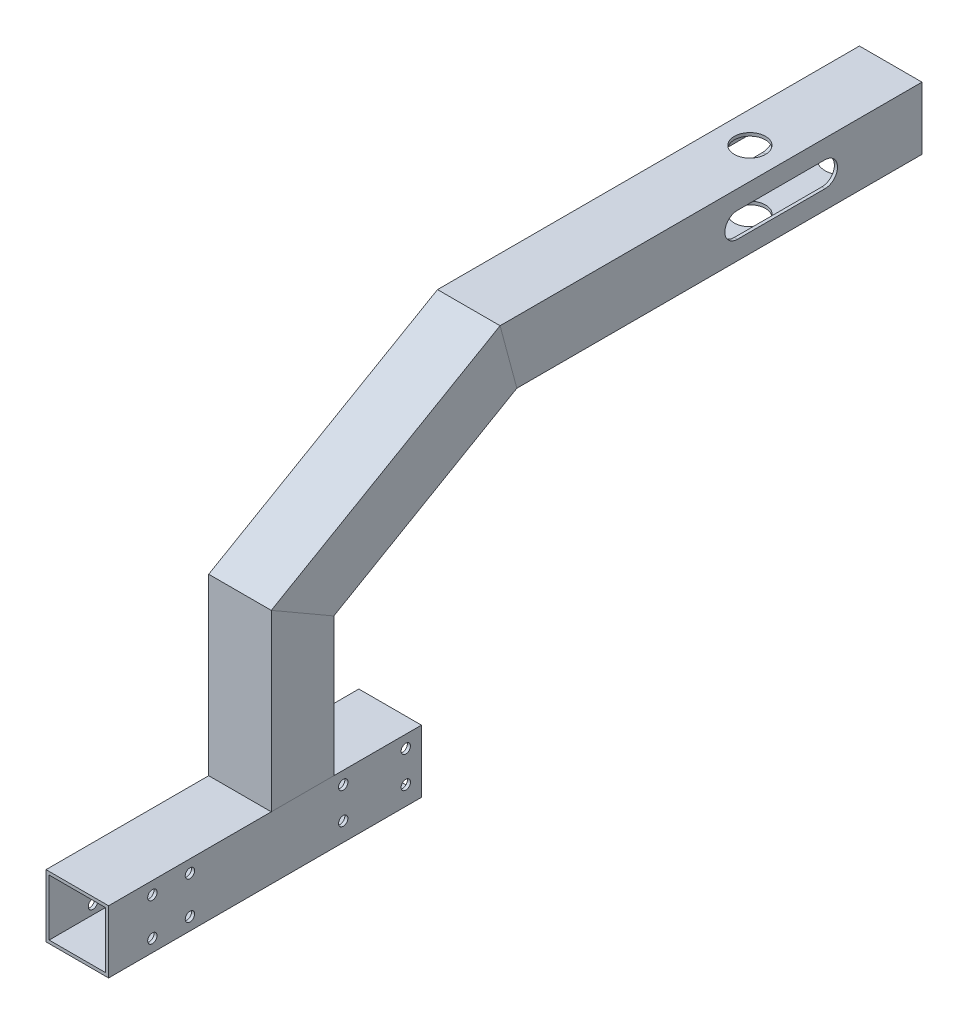
from build123d import *

# Parameters (mm, degrees)
SKETCH_11_W                = 20
SKETCH_11_H                = 20
SKETCH_11_W_2              = 18
SKETCH_11_H_2              = 18
F_20X20X1_14_DEPTH         = 100
SKETCH_11_ON_SEGMENT_2_W   = 20
SKETCH_11_ON_SEGMENT_2_H   = 20
SKETCH_11_ON_SEGMENT_2_W_2 = 18
SKETCH_11_ON_SEGMENT_2_H_2 = 18
F_20X20X1_14_2_DEPTH       = 70.164965809
SKETCH_11_ON_SEGMENT_3_W   = 20
SKETCH_11_ON_SEGMENT_3_H   = 20
SKETCH_11_ON_SEGMENT_3_W_2 = 18
SKETCH_11_ON_SEGMENT_3_H_2 = 18
F_20X20X1_14_3_DEPTH       = 89.954339629
SKETCH_11_ON_SEGMENT_4_W   = 20
SKETCH_11_ON_SEGMENT_4_H   = 20
SKETCH_11_ON_SEGMENT_4_W_2 = 18
SKETCH_11_ON_SEGMENT_4_H_2 = 18
F_20X20X1_14_4_DEPTH       = 136.971443132
SKETCH_12_R                = 1.5
CUT_EXTRUDE_1_DEPTH        = 283.248117797
SKETCH_13_R                = 5
CUT_EXTRUDE_2_DEPTH        = 279.035968896
CUT_EXTRUDE_3_DEPTH        = 283.248117797
SKETCH_15_R                = 6
CUT_EXTRUDE_4_DEPTH        = 1
SKETCH_16_R                = 1.5
CUT_EXTRUDE_5_DEPTH        = 1
SKETCH_17_R                = 1.5
CUT_EXTRUDE_6_DEPTH        = 20


with BuildPart() as part:
    # 草图11 → 铝管 20X20X1(14) (new body)
    with BuildSketch(Plane.YX):
        Rectangle(SKETCH_11_W, SKETCH_11_H)
        Rectangle(SKETCH_11_W_2, SKETCH_11_H_2, mode=Mode.SUBTRACT)
    extrude(amount=F_20X20X1_14_DEPTH)

    # 草图12 → 切除-拉伸1 (cut, through all)
    with BuildSketch(Plane(origin=(10, 0, 0), x_dir=(0, 0, -1), z_dir=(1, 0, 0))):
        with Locations((14, 6)):
            Circle(SKETCH_12_R)
        with Locations((14, -6)):
            Circle(SKETCH_12_R)
        with Locations((26, 6)):
            Circle(SKETCH_12_R)
        with Locations((26, -6)):
            Circle(SKETCH_12_R)
    extrude(amount=-CUT_EXTRUDE_1_DEPTH, mode=Mode.SUBTRACT)

    # 草图17 → 切除-拉伸6 (cut)
    with BuildSketch(Plane(origin=(10, 0, 0), x_dir=(0, 0, -1), z_dir=(1, 0, 0))):
        with Locations((95, -4)):
            Circle(SKETCH_17_R)
        with Locations((95, 6)):
            Circle(SKETCH_17_R)
        with Locations((75, 6)):
            Circle(SKETCH_17_R)
        with Locations((75, -4)):
            Circle(SKETCH_17_R)
    extrude(amount=-CUT_EXTRUDE_6_DEPTH, mode=Mode.SUBTRACT)


with BuildPart() as body_2:
    # 草图11 on segment 2 (carried to segment 2) → 20X20X1_14 2 (new body)
    with BuildSketch(Plane(origin=(0, -1, -62), x_dir=(0, 0, 1), z_dir=(0, 1, 0))):
        Rectangle(SKETCH_11_ON_SEGMENT_2_W, SKETCH_11_ON_SEGMENT_2_H)
        Rectangle(SKETCH_11_ON_SEGMENT_2_W_2, SKETCH_11_ON_SEGMENT_2_H_2, mode=Mode.SUBTRACT)
    extrude(amount=F_20X20X1_14_2_DEPTH)

    # 20X20X1_14 2 mitre 1
    split(bisect_by=Plane(origin=(0, 60, -62), x_dir=(1, 0, 0), z_dir=(0, -0.866025404, 0.5)), keep=Keep.TOP)

    # 20X20X1_14 2 mitre 2
    split(bisect_by=Plane(origin=(0, 10, -62), x_dir=(-1, 0, 0), z_dir=(0, 1, 0)), keep=Keep.TOP)


with BuildPart() as body_3:
    # 草图11 on segment 3 (carried to segment 3) → 20X20X1_14 3 (new body)
    with BuildSketch(Plane(origin=(0, 55.417517095, -54.062906784), x_dir=(0, 0.866025404, 0.5), z_dir=(0, 0.5, -0.866025404))):
        Rectangle(SKETCH_11_ON_SEGMENT_3_W, SKETCH_11_ON_SEGMENT_3_H)
        Rectangle(SKETCH_11_ON_SEGMENT_3_W_2, SKETCH_11_ON_SEGMENT_3_H_2, mode=Mode.SUBTRACT)
    extrude(amount=F_20X20X1_14_3_DEPTH)

    # 20X20X1_14 3 mitre 1
    split(bisect_by=Plane(origin=(0, 60, -62), x_dir=(-1, 0, 0), z_dir=(0, 0.866025404, -0.5)), keep=Keep.TOP)

    # 20X20X1_14 3 mitre 2
    split(bisect_by=Plane(origin=(0, 98, -127.817930688), x_dir=(0, -0.965925826, -0.258819045), z_dir=(0, -0.258819045, 0.965925826)), keep=Keep.TOP)


with BuildPart() as body_4:
    # 草图11 on segment 4 (carried to segment 4) → 20X20X1_14 4 (new body)
    with BuildSketch(Plane(origin=(0, 98, -123.028556868), x_dir=(0, 1, 0), z_dir=(0, 0, -1))):
        Rectangle(SKETCH_11_ON_SEGMENT_4_W, SKETCH_11_ON_SEGMENT_4_H)
        Rectangle(SKETCH_11_ON_SEGMENT_4_W_2, SKETCH_11_ON_SEGMENT_4_H_2, mode=Mode.SUBTRACT)
    extrude(amount=F_20X20X1_14_4_DEPTH)

    # 20X20X1_14 4 mitre 1
    split(bisect_by=Plane(origin=(0, 98, -127.817930688), x_dir=(0, 0.965925826, 0.258819045), z_dir=(0, 0.258819045, -0.965925826)), keep=Keep.TOP)

    # 草图13 → 切除-拉伸2 (cut, through all)
    with BuildSketch(Plane.XZ.offset(-88)):
        with Locations(Location((0, -215, 0), (0, 0, 270))):
            Circle(SKETCH_13_R)
    extrude(amount=-CUT_EXTRUDE_2_DEPTH, mode=Mode.SUBTRACT)

    # 草图14 → 切除-拉伸3 (cut, through all)
    with BuildSketch(Plane(origin=(10, 0, 0), x_dir=(0, 0, -1), z_dir=(1, 0, 0))):
        with BuildLine():
            Line((201, 102), (229, 102))
            ThreePointArc((229, 102), (233, 98), (229, 94))
            Line((229, 94), (201, 94))
            ThreePointArc((201, 94), (197, 98), (201, 102))
        make_face()
    extrude(amount=-CUT_EXTRUDE_3_DEPTH, mode=Mode.SUBTRACT)

    # 草图15 → 切除-拉伸4 (cut)
    with BuildSketch(Plane.XZ.offset(-88)):
        with Locations(Location((0, -245, 0), (0, 0, 270))):
            Circle(SKETCH_15_R)
    extrude(amount=-CUT_EXTRUDE_4_DEPTH, mode=Mode.SUBTRACT)

    # 草图16 → 切除-拉伸5 (cut)
    with BuildSketch(Plane.XZ.offset(-88)):
        with Locations(Location((6, -254, 0), (0, 0, 270))):
            Circle(SKETCH_16_R)
    extrude(amount=-CUT_EXTRUDE_5_DEPTH, mode=Mode.SUBTRACT)


solid = Compound([part.part, body_2.part, body_3.part, body_4.part])
